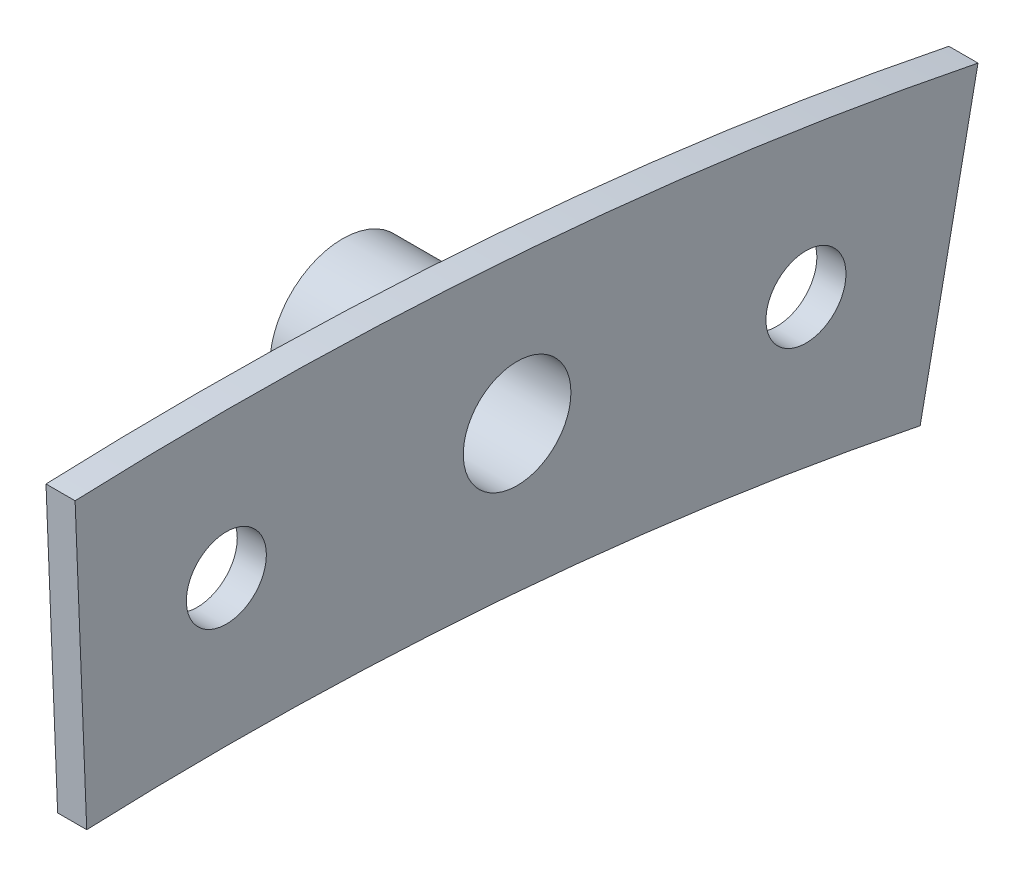
from build123d import *

# Parameters (mm, degrees)
SKETCH1_R           = 3.4925
SKETCH1_R_2         = 4.699
BOSS_EXTRUDE1_DEPTH = 2.54
SKETCH2_R           = 6.35
BOSS_EXTRUDE2_DEPTH = 12.7
SKETCH4_R           = 4.699
CUT_EXTRUDE1_DEPTH  = 6.35


with BuildPart() as part:
    # Sketch1 → Boss-Extrude1 (new body)
    with BuildSketch(Plane(origin=(0, 0, 0), x_dir=(0, 0, -1), z_dir=(1, 0, 0))):
        with BuildLine():
            Line((-12.189561356, 304.55616), (-13.205358136, 329.93584))
            ThreePointArc((-13.205358136, 329.93584), (26.39485874, 329.14336), (65.615293749, 323.615007727))
            Line((65.615293749, 323.615007727), (60.567963461, 298.721545594))
            ThreePointArc((60.567963461, 298.721545594), (24.364484991, 303.82464), (-12.189561356, 304.55616))
        make_face()
        with Locations((0, 317.5)):
            Circle(SKETCH1_R, mode=Mode.SUBTRACT)
        with Locations((25.379671865, 316.484)):
            Circle(SKETCH1_R_2, mode=Mode.SUBTRACT)
        with Locations((50.596913831, 313.4425024)):
            Circle(SKETCH1_R, mode=Mode.SUBTRACT)
    extrude(amount=BOSS_EXTRUDE1_DEPTH)

    # Sketch2 → Boss-Extrude2 (add)
    with BuildSketch(Plane.ZY):
        with Locations((-25.379671865, 316.484)):
            Circle(SKETCH2_R)
    extrude(amount=BOSS_EXTRUDE2_DEPTH)

    # Sketch4 → Cut-Extrude1 (cut)
    with BuildSketch(Plane(origin=(0, 0, 0), x_dir=(0, 0, -1), z_dir=(1, 0, 0))):
        with Locations((25.379671865, 316.484)):
            Circle(SKETCH4_R)
    extrude(amount=-CUT_EXTRUDE1_DEPTH, mode=Mode.SUBTRACT)


solid = part.part
